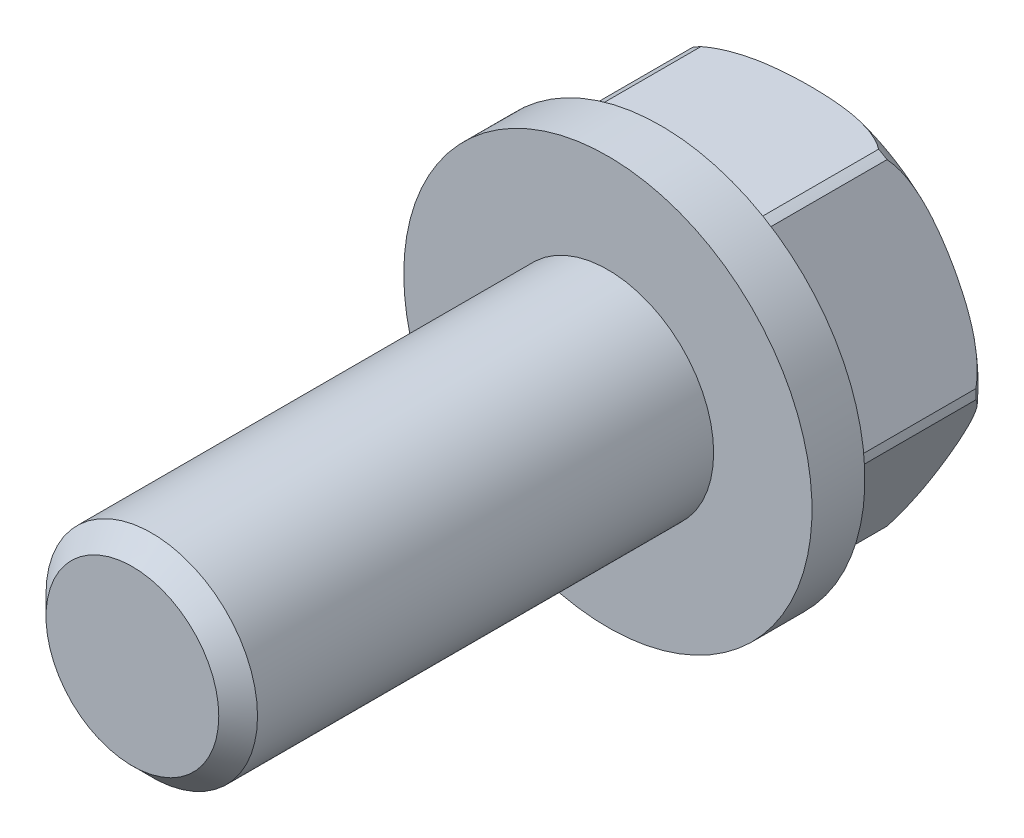
from build123d import *

# Parameters (mm, degrees)
CUT_EXTRUDE1_DEPTH = 9.271
CHAMFER1_SIZE      = 1.16332


with BuildPart() as part:
    # Sketch1 → Revolve2 (revolve)
    with BuildSketch(Plane(origin=(0, 0, 0), x_dir=(1, 0, 0), z_dir=(0, 1, 0))):
        Polygon((0, 14.782898833), (0, -26.212701167), (-6.35, -26.212701167), (-6.35, 2.336898833), (-12.2555, 2.336898833), (-12.2555, 5.511898833), (-11.176, 5.511898833), (-11.176, 14.782898833), align=None)
    revolve(axis=Axis((0, 0, -24.892494163), (0, 0, 1)))

    # Sketch3 → Cut-Extrude1 (cut)
    with BuildSketch(Plane(origin=(0, 0, -14.782898833), x_dir=(-1, 0, 0), z_dir=(0, 0, -1))):
        with BuildLine():
            ThreePointArc((5.334, 9.820968384), (0, 11.176), (-5.334, 9.820968384))
            Line((-5.334, 9.820968384), (5.334, 9.820968384))
        make_face()
        with BuildLine():
            Line((-11.17220811, 0.291104688), (-5.83820811, 9.529863696))
            ThreePointArc((-5.83820811, 9.529863696), (-9.678699913, 5.588), (-11.17220811, 0.291104688))
        make_face()
        with BuildLine():
            Line((-5.83820811, -9.529863696), (-11.17220811, -0.291104688))
            ThreePointArc((-11.17220811, -0.291104688), (-9.678699913, -5.588), (-5.83820811, -9.529863696))
        make_face()
        with BuildLine():
            Line((5.334, -9.820968384), (-5.334, -9.820968384))
            ThreePointArc((-5.334, -9.820968384), (0, -11.176), (5.334, -9.820968384))
        make_face()
        with BuildLine():
            ThreePointArc((5.83820811, -9.529863696), (9.678699913, -5.588), (11.17220811, -0.291104688))
            Line((11.17220811, -0.291104688), (5.83820811, -9.529863696))
        make_face()
        with BuildLine():
            ThreePointArc((11.17220811, 0.291104688), (9.678699913, 5.588), (5.83820811, 9.529863696))
            Line((5.83820811, 9.529863696), (11.17220811, 0.291104688))
        make_face()
    extrude(amount=-CUT_EXTRUDE1_DEPTH, mode=Mode.SUBTRACT)

    # Sketch4 → Cut-Revolve1 (revolve, cut)
    with BuildSketch(Plane(origin=(0, 0, 0), x_dir=(1, 0, 0), z_dir=(0, 1, 0))):
        with BuildLine():
            Line((8.6995, 14.782898833), (11.176, 14.782898833))
            Line((11.176, 14.782898833), (11.176, 13.258898833))
            ThreePointArc((11.176, 13.258898833), (10.119876474, 14.316854353), (8.6995, 14.782898833))
        make_face()
    revolve(axis=Axis((0, 0, -20.186462401), (0, 0, 1)), mode=Mode.SUBTRACT)

    # Chamfer1
    chamfer1_edges = [part.edges().sort_by_distance(p)[0] for p in [
        (6.35, 0, 26.212701167),
    ]]
    chamfer(chamfer1_edges, length=CHAMFER1_SIZE)


solid = part.part
